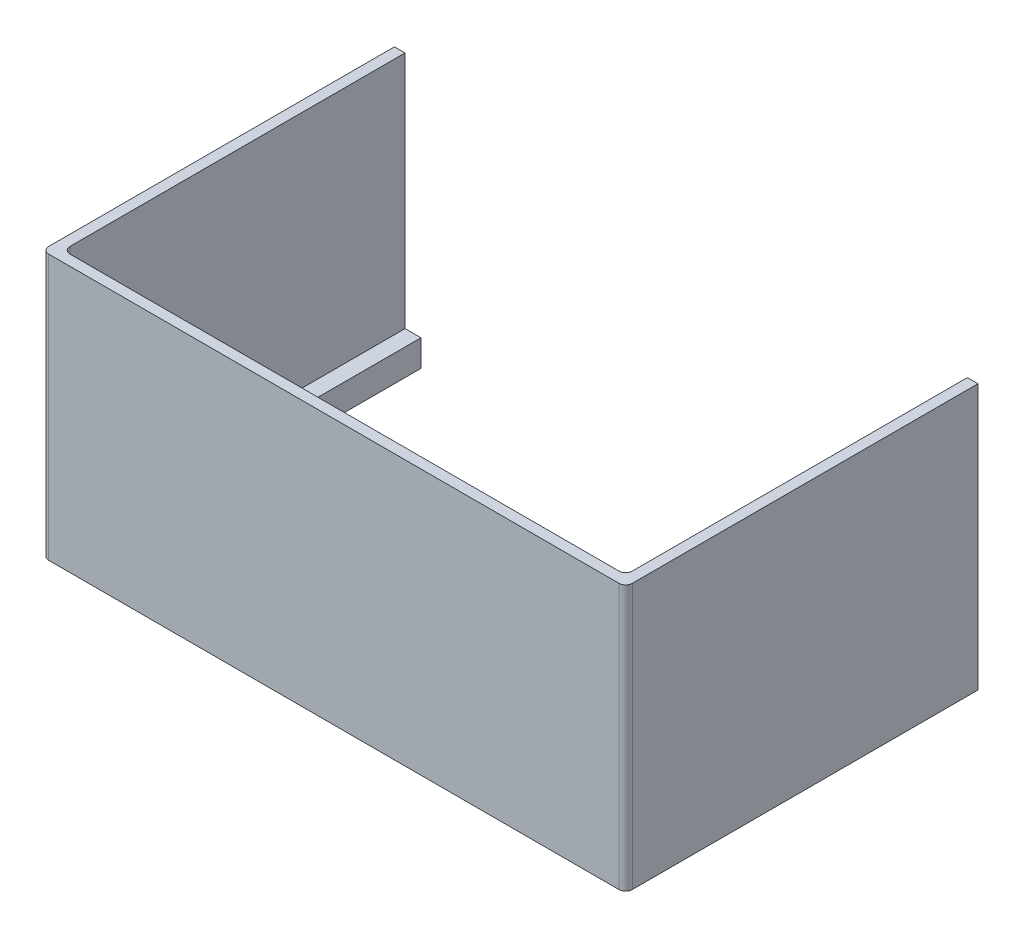
from build123d import *

# Parameters (mm, degrees)
SKETCH1_W           = 139.7
SKETCH1_H           = 154.20848
BOSS_EXTRUDE1_DEPTH = 6.35
SKETCH2_W           = 127
SKETCH2_H           = 141.50848
CUT_EXTRUDE1_DEPTH  = 6.35
SKETCH3_W           = 139.7
SKETCH3_H           = 154.20848
SKETCH3_W_2         = 134.62
SKETCH3_H_2         = 149.12848
BOSS_EXTRUDE2_DEPTH = 57.15
SKETCH4_W           = 139.7
SKETCH4_H           = 69.85
CUT_EXTRUDE2_DEPTH  = 64.5
SKETCH5_W           = 2.4765
SKETCH5_H           = 3.429
CUT_EXTRUDE3_DEPTH  = 3.81
FILLET1_R           = 1.5875


with BuildPart() as part:
    # Sketch1 → Boss-Extrude1 (new body)
    with BuildSketch(Plane(origin=(0, 0, 0), x_dir=(1, 0, 0), z_dir=(0, 1, 0))):
        Rectangle(SKETCH1_W, SKETCH1_H)
    extrude(amount=BOSS_EXTRUDE1_DEPTH)

    # Sketch2 → Cut-Extrude1 (cut)
    with BuildSketch(Plane(origin=(0, 6.35, 0), x_dir=(1, 0, 0), z_dir=(0, 1, 0))):
        Rectangle(SKETCH2_W, SKETCH2_H)
    extrude(amount=-CUT_EXTRUDE1_DEPTH, mode=Mode.SUBTRACT)

    # Sketch3 → Boss-Extrude2 (add)
    with BuildSketch(Plane(origin=(0, 6.35, 0), x_dir=(1, 0, 0), z_dir=(0, 1, 0))):
        Rectangle(SKETCH3_W, SKETCH3_H)
        Rectangle(SKETCH3_W_2, SKETCH3_H_2, mode=Mode.SUBTRACT)
    extrude(amount=BOSS_EXTRUDE2_DEPTH)

    # Sketch4 → Cut-Extrude2 (cut, through all)
    with BuildSketch(Plane(origin=(0, 63.5, 0), x_dir=(1, 0, 0), z_dir=(0, 1, 0))):
        with Locations((0, 42.17924)):
            Rectangle(SKETCH4_W, SKETCH4_H)
    extrude(amount=-CUT_EXTRUDE2_DEPTH, mode=Mode.SUBTRACT)

    # Sketch5 → Cut-Extrude3 (cut)
    with BuildSketch(Plane(origin=(0, 0, -7.25424), x_dir=(-1, 0, 0), z_dir=(0, 0, -1))):
        with Locations((66.19875, 3.175)):
            Rectangle(SKETCH5_W, SKETCH5_H)
        with Locations((-66.19875, 3.175)):
            Rectangle(SKETCH5_W, SKETCH5_H)
    extrude(amount=-CUT_EXTRUDE3_DEPTH, mode=Mode.SUBTRACT)

    # Fillet1
    fillet1_edges = [part.edges().sort_by_distance(p)[0] for p in [
        (-67.31, 34.925, 74.56424),
        (67.31, 34.925, 74.56424),
        (69.85, 31.75, 77.10424),
        (-69.85, 31.75, 77.10424),
    ]]
    fillet(fillet1_edges, radius=FILLET1_R)


solid = part.part
